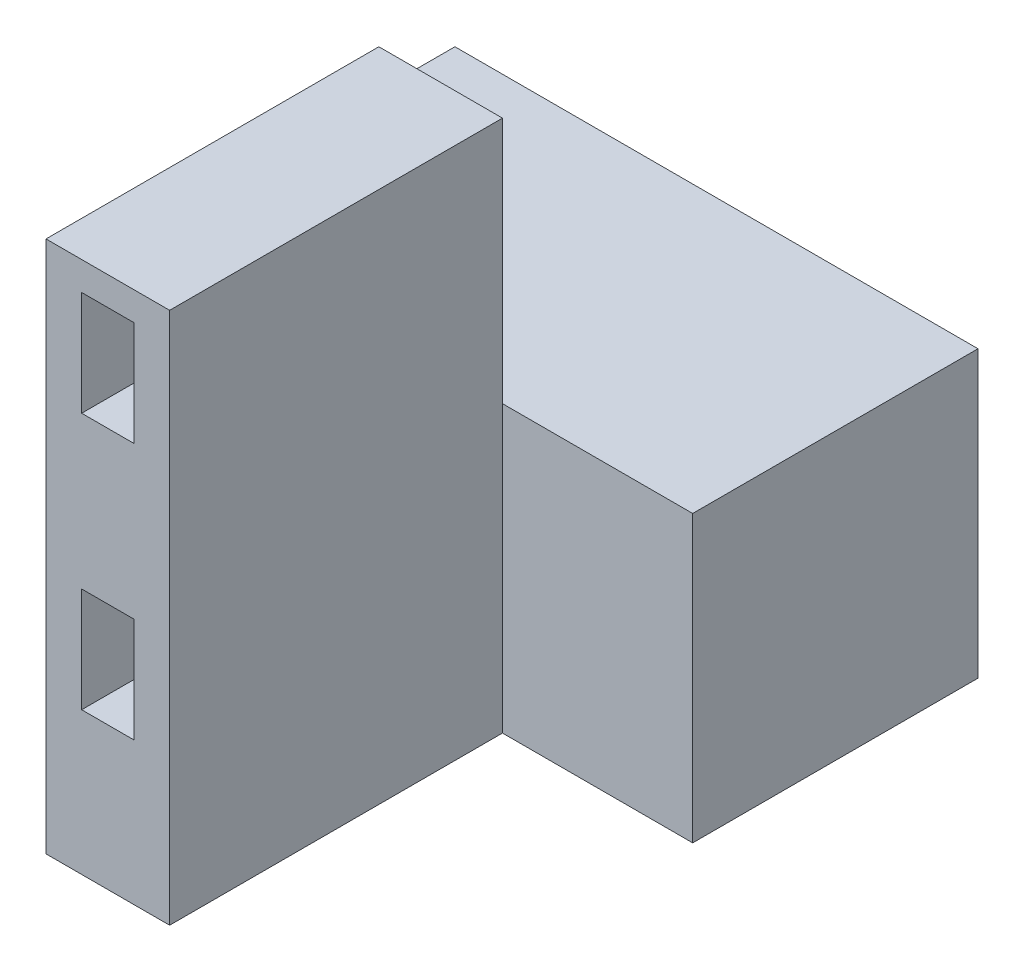
from build123d import *

# Parameters (mm, degrees)
SKETCH1_W           = 55
SKETCH1_H           = 30
BOSS_EXTRUDE1_DEPTH = 30
SKETCH2_W           = 13
SKETCH2_H           = 56
BOSS_EXTRUDE2_DEPTH = 35
SKETCH3_W           = 5.5
SKETCH3_H           = 11
CUT_EXTRUDE1_DEPTH  = 22


with BuildPart() as part:
    # Sketch1 → Boss-Extrude1 (new body)
    with BuildSketch(Plane(origin=(0, 0, 0), x_dir=(1, 0, 0), z_dir=(0, 1, 0))):
        Rectangle(SKETCH1_W, SKETCH1_H)
    extrude(amount=BOSS_EXTRUDE1_DEPTH)

    # Sketch2 → Boss-Extrude2 (add)
    with BuildSketch(Plane.XY.offset(15)):
        with Locations((1, 28)):
            Rectangle(SKETCH2_W, SKETCH2_H)
    extrude(amount=BOSS_EXTRUDE2_DEPTH)

    # Sketch3 → Cut-Extrude1 (cut)
    with BuildSketch(Plane.XY.offset(50)):
        with Locations((1, 20.5)):
            Rectangle(SKETCH3_W, SKETCH3_H)
        with Locations((1, 47.5)):
            Rectangle(SKETCH3_W, SKETCH3_H)
    extrude(amount=-CUT_EXTRUDE1_DEPTH, mode=Mode.SUBTRACT)


solid = part.part
